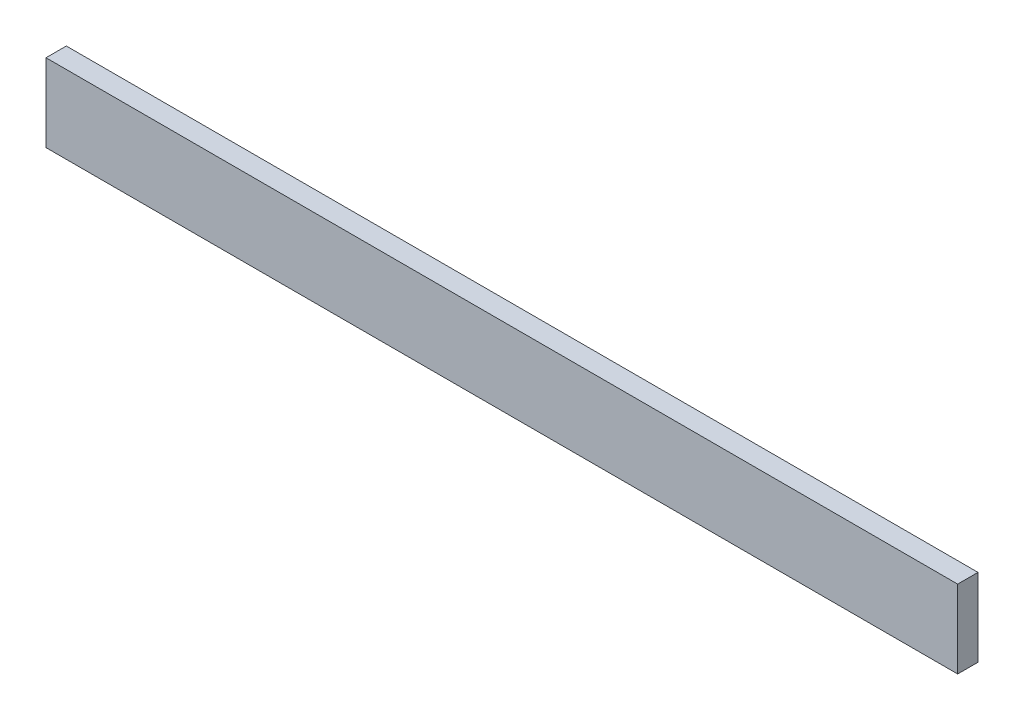
from build123d import *

# Parameters (mm, degrees)
SKETCH1_W           = 448.417155537
SKETCH1_H           = 38.292622135
BOSS_EXTRUDE1_DEPTH = 10


with BuildPart() as part:
    # Sketch1 → Boss-Extrude1 (new body)
    with BuildSketch(Plane.XY):
        with Locations((224.208577769, 19.146311068)):
            Rectangle(SKETCH1_W, SKETCH1_H)
    extrude(amount=BOSS_EXTRUDE1_DEPTH)


solid = part.part
